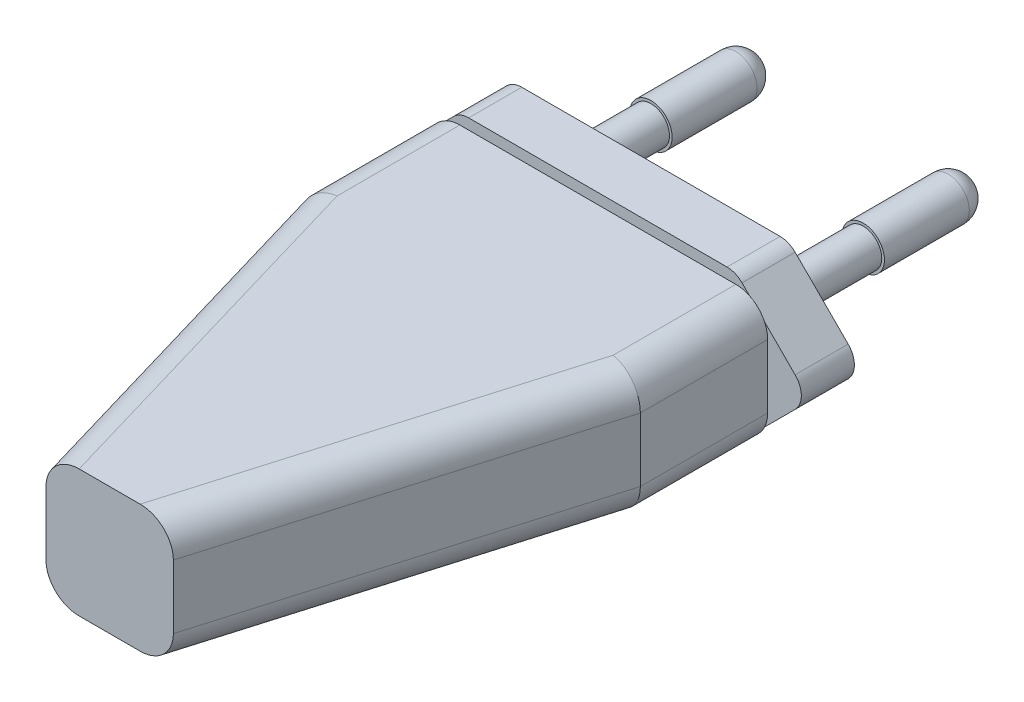
from build123d import *

# Parameters (mm, degrees)
BOSS_EXTRUDE1_DEPTH = 12
FILLET1_R           = 3
BOSS_EXTRUDE2_DEPTH = 5
FILLET2_R           = 2
SKETCH4_R           = 1.75
BOSS_EXTRUDE3_DEPTH = 10
SKETCH5_R           = 2
BOSS_EXTRUDE4_DEPTH = 10
FILLET3_R           = 2


with BuildPart() as part:
    # Sketch1 → Boss-Extrude1 (new body)
    with BuildSketch(Plane(origin=(0, 0, 0), x_dir=(1, 0, 0), z_dir=(0, 1, 0))):
        Polygon((-6, 0), (6, 0), (11, 17), (16, 34), (16, 46), (-16, 46), (-16, 34), (-11, 17), align=None)
    extrude(amount=BOSS_EXTRUDE1_DEPTH)

    # Fillet1
    fillet1_edges = [part.edges().sort_by_distance(p)[0] for p in [
        (11, 12, -17),
        (16, 12, -40),
        (-16, 12, -40),
        (-11, 12, -17),
        (-11, 0, -17),
        (-16, 0, -40),
        (16, 0, -40),
        (11, 0, -17),
    ]]
    fillet(fillet1_edges, radius=FILLET1_R)

    # Sketch3 → Boss-Extrude2 (add)
    with BuildSketch(Plane(origin=(0, 0, -46), x_dir=(-1, 0, 0), z_dir=(0, 0, -1))):
        Polygon((-13, 13), (13, 13), (20, 6), (13, -1), (-13, -1), (-20, 6), align=None)
    extrude(amount=BOSS_EXTRUDE2_DEPTH)

    # Fillet2
    fillet2_edges = [part.edges().sort_by_distance(p)[0] for p in [
        (13, 13, -48.5),
        (20, 6, -48.5),
        (13, -1, -48.5),
        (-13, -1, -48.5),
        (-20, 6, -48.5),
        (-13, 13, -48.5),
    ]]
    fillet(fillet2_edges, radius=FILLET2_R)

    # Sketch4 → Boss-Extrude3 (add)
    with BuildSketch(Plane(origin=(0, 0, -51), x_dir=(-1, 0, 0), z_dir=(0, 0, -1))):
        with Locations((-10, 6)):
            Circle(SKETCH4_R)
        with Locations((10, 6)):
            Circle(SKETCH4_R)
    extrude(amount=BOSS_EXTRUDE3_DEPTH)

    # Sketch5 → Boss-Extrude4 (add)
    with BuildSketch(Plane(origin=(0, 0, -61), x_dir=(-1, 0, 0), z_dir=(0, 0, -1))):
        with Locations((10, 6)):
            Circle(SKETCH5_R)
        with Locations((-10, 6)):
            Circle(SKETCH5_R)
    extrude(amount=BOSS_EXTRUDE4_DEPTH)

    # Fillet3
    fillet3_edges = [part.edges().sort_by_distance(p)[0] for p in [
        (-8, 6, -71),
        (12, 6, -71),
    ]]
    fillet(fillet3_edges, radius=FILLET3_R)


solid = part.part
